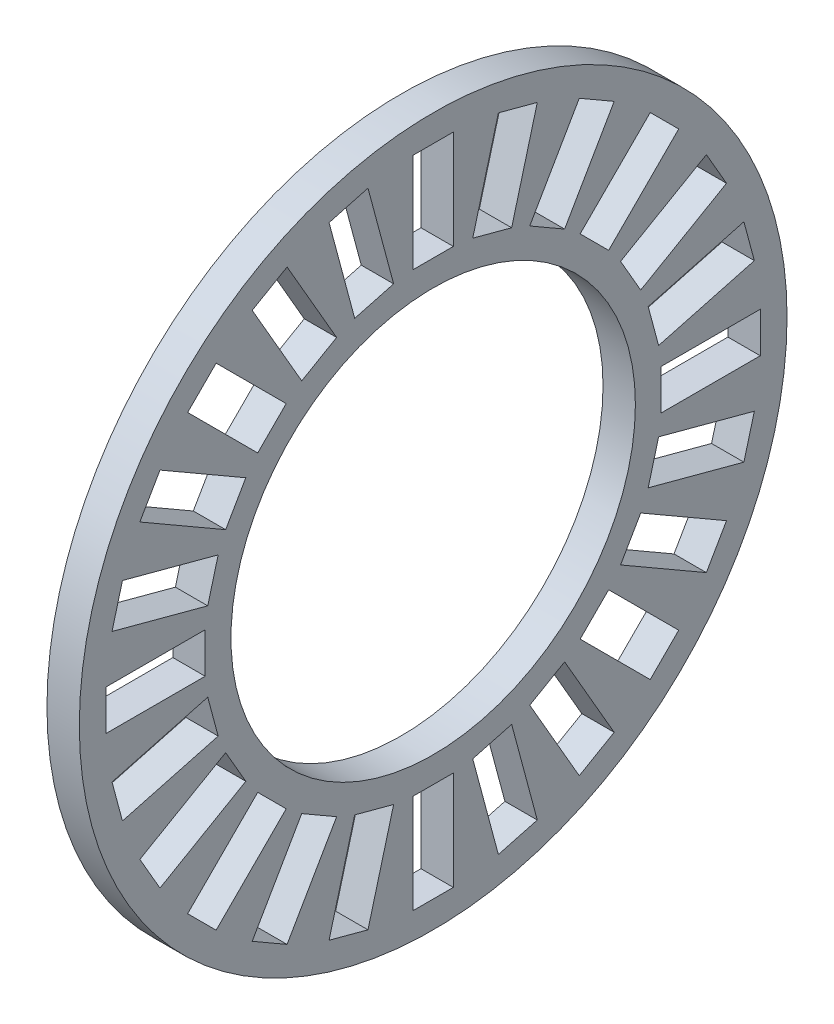
from build123d import *

# Parameters (mm, degrees)
BOSS_EXTRUDE1_DEPTH      = 0.8
BOSS_EXTRUDE1_DEPTH_BACK = 0.8
SKETCH1_R                = 17.5
SKETCH1_R_2              = 10
SKETCH1_W                = 4.9
SKETCH1_H                = 1.992179872
SKETCH1_W_2              = 1.992179872
SKETCH1_H_2              = 4.9


with BuildPart() as part:
    # Sketch1 → Boss-Extrude1 (new, two sides: drawn at the far end of the back side and taken through both)
    with BuildSketch(Plane(origin=(0, 0, 0), x_dir=(0, 0, -1), z_dir=(1, 0, 0)).offset(-BOSS_EXTRUDE1_DEPTH_BACK)):
        Circle(SKETCH1_R)
        Circle(SKETCH1_R_2, mode=Mode.SUBTRACT)
        with Locations((13.725, 0)):
            Rectangle(SKETCH1_W, SKETCH1_H, mode=Mode.SUBTRACT)
        Polygon((10.633006645, 3.880333728), (11.148620737, 1.956035739), (15.881657286, 3.22424906), (15.366043194, 5.148547049), align=None, mode=Mode.SUBTRACT)
        Polygon((10.633006645, -3.880333728), (15.366043194, -5.148547049), (15.881657286, -3.22424906), (11.148620737, -1.956035739), align=None, mode=Mode.SUBTRACT)
        Polygon((9.26639146, 6.500139189), (10.262481396, 4.774860811), (14.506005874, 7.224860811), (13.509915938, 8.950139189), align=None, mode=Mode.SUBTRACT)
        Polygon((9.26639146, -6.500139189), (13.509915938, -8.950139189), (14.506005874, -7.224860811), (10.262481396, -4.774860811), align=None, mode=Mode.SUBTRACT)
        Polygon((7.26828701, 8.676970906), (8.676970906, 7.26828701), (12.141794134, 10.733110237), (10.733110237, 12.141794134), align=None, mode=Mode.SUBTRACT)
        Polygon((7.26828701, -8.676970906), (10.733110237, -12.141794134), (12.141794134, -10.733110237), (8.676970906, -7.26828701), align=None, mode=Mode.SUBTRACT)
        Polygon((4.774860811, 10.262481396), (6.500139189, 9.26639146), (8.950139189, 13.509915938), (7.224860811, 14.506005874), align=None, mode=Mode.SUBTRACT)
        Polygon((4.774860811, -10.262481396), (7.224860811, -14.506005874), (8.950139189, -13.509915938), (6.500139189, -9.26639146), align=None, mode=Mode.SUBTRACT)
        Polygon((1.956035739, 11.148620737), (3.880333728, 10.633006645), (5.148547049, 15.366043194), (3.22424906, 15.881657286), align=None, mode=Mode.SUBTRACT)
        Polygon((1.956035739, -11.148620737), (3.22424906, -15.881657286), (5.148547049, -15.366043194), (3.880333728, -10.633006645), align=None, mode=Mode.SUBTRACT)
        with Locations((0, 13.725)):
            Rectangle(SKETCH1_W_2, SKETCH1_H_2, mode=Mode.SUBTRACT)
        with Locations((0, -13.725)):
            Rectangle(SKETCH1_W_2, SKETCH1_H_2, mode=Mode.SUBTRACT)
        Polygon((-5.148547049, 15.366043194), (-3.880333728, 10.633006645), (-1.956035739, 11.148620737), (-3.22424906, 15.881657286), align=None, mode=Mode.SUBTRACT)
        Polygon((-5.148547049, -15.366043194), (-3.22424906, -15.881657286), (-1.956035739, -11.148620737), (-3.880333728, -10.633006645), align=None, mode=Mode.SUBTRACT)
        Polygon((-8.950139189, 13.509915938), (-6.500139189, 9.26639146), (-4.774860811, 10.262481396), (-7.224860811, 14.506005874), align=None, mode=Mode.SUBTRACT)
        Polygon((-8.950139189, -13.509915938), (-7.224860811, -14.506005874), (-4.774860811, -10.262481396), (-6.500139189, -9.26639146), align=None, mode=Mode.SUBTRACT)
        Polygon((-12.141794134, 10.733110237), (-8.676970906, 7.26828701), (-7.26828701, 8.676970906), (-10.733110237, 12.141794134), align=None, mode=Mode.SUBTRACT)
        Polygon((-12.141794134, -10.733110237), (-10.733110237, -12.141794134), (-7.26828701, -8.676970906), (-8.676970906, -7.26828701), align=None, mode=Mode.SUBTRACT)
        Polygon((-14.506005874, 7.224860811), (-10.262481396, 4.774860811), (-9.26639146, 6.500139189), (-13.509915938, 8.950139189), align=None, mode=Mode.SUBTRACT)
        Polygon((-14.506005874, -7.224860811), (-13.509915938, -8.950139189), (-9.26639146, -6.500139189), (-10.262481396, -4.774860811), align=None, mode=Mode.SUBTRACT)
        Polygon((-15.881657286, 3.22424906), (-11.148620737, 1.956035739), (-10.633006645, 3.880333728), (-15.366043194, 5.148547049), align=None, mode=Mode.SUBTRACT)
        Polygon((-15.881657286, -3.22424906), (-15.366043194, -5.148547049), (-10.633006645, -3.880333728), (-11.148620737, -1.956035739), align=None, mode=Mode.SUBTRACT)
        with Locations((-13.725, 0)):
            Rectangle(SKETCH1_W, SKETCH1_H, mode=Mode.SUBTRACT)
    extrude(amount=BOSS_EXTRUDE1_DEPTH + BOSS_EXTRUDE1_DEPTH_BACK)


solid = part.part
